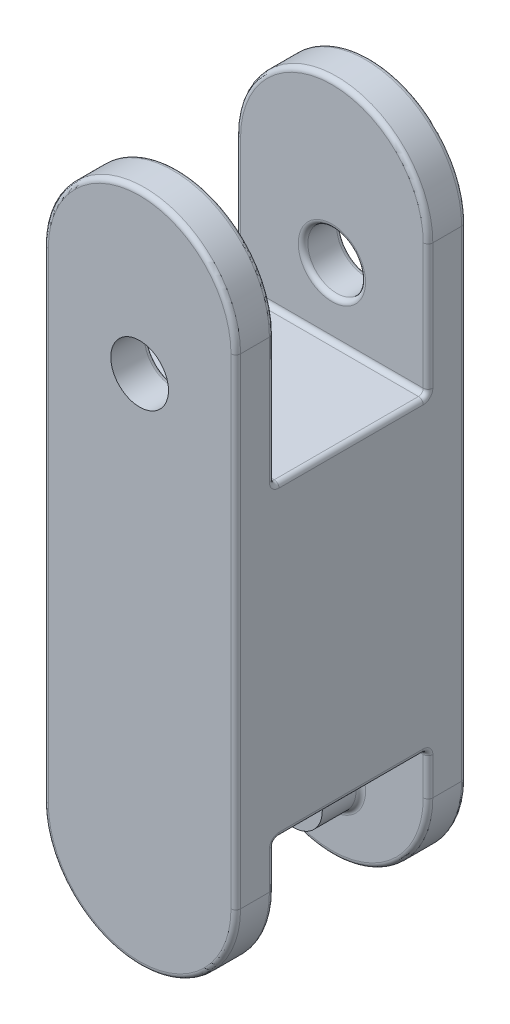
from build123d import *

# Parameters (mm, degrees)
BOSS_EXTRUDE1_DEPTH = 50.8
SKETCH3_R           = 38.1
CUT_EXTRUDE1_DEPTH  = 101.6
SKETCH6_W           = 254
SKETCH6_H           = 406.4
BOSS_EXTRUDE5_DEPTH = 101.6
SKETCH7_R           = 38.1
BOSS_EXTRUDE6_DEPTH = 50.8
FILLET1_R           = 6.35
FILLET2_R           = 6.35
FILLET3_R           = 6.35


with BuildPart() as part:
    # Sketch1 → Boss-Extrude1 (new body)
    with BuildSketch(Plane.XY):
        with BuildLine():
            Line((-127, -317.5), (-127, 317.5))
            ThreePointArc((-127, 317.5), (0, 444.5), (127, 317.5))
            Line((127, 317.5), (127, -317.5))
            ThreePointArc((127, -317.5), (0, -444.5), (-127, -317.5))
        make_face()
    extrude(amount=BOSS_EXTRUDE1_DEPTH)

    # Sketch3 → Cut-Extrude1 (cut)
    with BuildSketch(Plane.XY.offset(50.8)):
        with Locations((0, 234.322541714)):
            Circle(SKETCH3_R)
    extrude(amount=-CUT_EXTRUDE1_DEPTH, mode=Mode.SUBTRACT)

    # Sketch6 → Boss-Extrude5 (add)
    with BuildSketch(Plane.XY.offset(50.8)):
        with Locations((0, -58.363097233)):
            Rectangle(SKETCH6_W, SKETCH6_H)
    extrude(amount=BOSS_EXTRUDE5_DEPTH)

    # Sketch7 → Boss-Extrude6 (add)
    with BuildSketch(Plane.XY.offset(50.8)):
        with Locations((0, -348.219968447)):
            Circle(SKETCH7_R)
    extrude(amount=BOSS_EXTRUDE6_DEPTH)

    # Mirror3: part across plane


with BuildPart() as part_1:
    add(part.part)
    add(part.part.mirror(Plane(origin=(0, 0, 152.4), x_dir=(1, 0, 0), z_dir=(0, 0, -1))))

    # Fillet1
    fillet1_edges = [part_1.edges().sort_by_distance(p)[0] for p in [
        (-127, 0, 304.8),
        (0, -444.5, 304.8),
        (127, 0, 304.8),
        (0, 444.5, 304.8),
    ]]
    fillet(fillet1_edges, radius=FILLET1_R)

    # Fillet2
    fillet2_edges = [part_1.edges().sort_by_distance(p)[0] for p in [
        (-38.1, 234.322541714, 0),
        (-127, 0, 0),
        (0, 444.5, 0),
        (127, 0, 0),
        (0, -444.5, 0),
    ]]
    fillet(fillet2_edges, radius=FILLET2_R)

    # Fillet3
    fillet3_edges = [part_1.edges().sort_by_distance(p)[0] for p in [
        (0, 444.5, 50.8),
        (-38.1, 234.322541714, 50.8),
        (-127, -289.531548617, 50.8),
        (127, 231.168451383, 50.8),
        (-127, 231.168451383, 50.8),
        (-127, 144.836902767, 152.4),
        (0, -261.563097233, 50.8),
        (-127, -261.563097233, 152.4),
        (127, -261.563097233, 152.4),
        (0, 144.836902767, 50.8),
        (127, 144.836902767, 152.4),
        (-38.1, -348.219968447, 50.8),
        (0, 144.836902767, 254),
        (-127, 231.168451383, 254),
        (-38.1, 234.322541714, 254),
        (0, -444.5, 254),
        (127, -289.531548617, 254),
        (127, 231.168451383, 254),
        (0, 444.5, 254),
        (-38.1, -348.219968447, 254),
        (0, -261.563097233, 254),
        (-127, -289.531548617, 254),
        (0, -444.5, 50.8),
        (127, -289.531548617, 50.8),
    ]]
    fillet(fillet3_edges, radius=FILLET3_R)


solid = part_1.part
